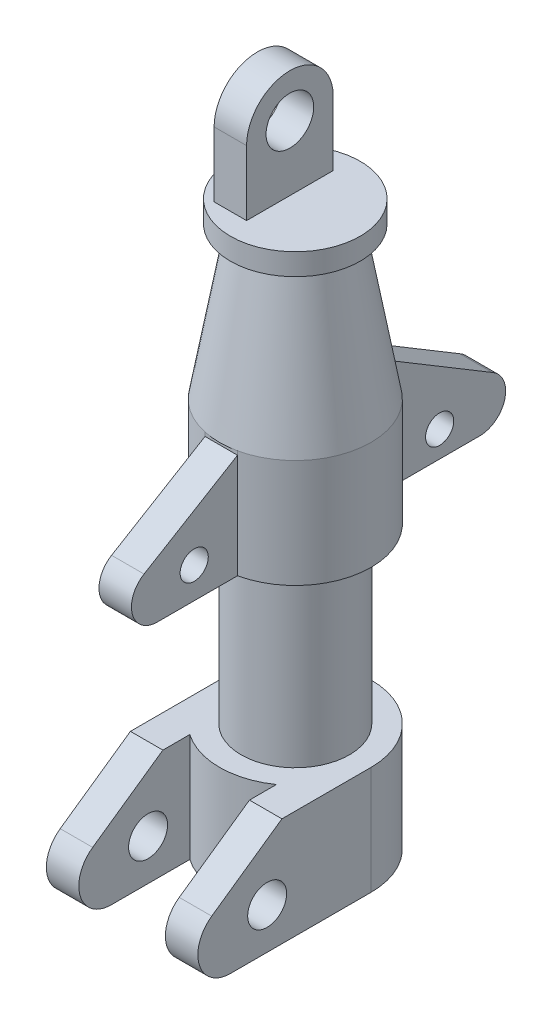
from build123d import *

# Parameters (mm, degrees)
SKETCH2_W           = 15
SKETCH2_H           = 93.194890567
BOSS_EXTRUDE2_DEPTH = 50
SKETCH3_R           = 9
CUT_EXTRUDE6_DEPTH  = 105
BOSS_EXTRUDE4_DEPTH = 50
SKETCH7_R           = 6.5
CUT_EXTRUDE7_DEPTH  = 105
SKETCH8_R           = 20
CUT_EXTRUDE8_DEPTH  = 235
SKETCH11_W          = 15
SKETCH11_H          = 40
BOSS_EXTRUDE5_DEPTH = 60
SKETCH12_R          = 11
CUT_EXTRUDE9_DEPTH  = 60


with BuildPart() as part:
    # Sketch1 → Revolve1 (revolve)
    with BuildSketch(Plane.XY):
        Polygon((0, 260), (30, 260), (30, 250), (22.65711135, 250), (35, 180), (35, 130), (25, 130), (25, 50), (35, 50), (35, 0), (0, 0), align=None)
    revolve(axis=Axis((0, 462.148353897, 0), (0, -1, 0)))

    # Sketch2 → Boss-Extrude2 (add)
    with BuildSketch(Plane(origin=(0, 0, 0), x_dir=(1, 0, 0), z_dir=(0, 1, 0))):
        with Locations((-27.5, -46.597445284)):
            Rectangle(SKETCH2_W, SKETCH2_H)
        with Locations((27.5, -46.597445284)):
            Rectangle(SKETCH2_W, SKETCH2_H)
    extrude(amount=BOSS_EXTRUDE2_DEPTH)

    # Sketch3 → Cut-Extrude6 (cut)
    with BuildSketch(Plane.ZY.offset(35)):
        with Locations((48, 19)):
            Circle(SKETCH3_R)
        with BuildLine():
            Line((73.603646545, 27.287280664), (41.166521698, 50))
            Line((41.166521698, 50), (93.194890567, 50))
            Line((93.194890567, 50), (93.194890567, 0))
            Line((93.194890567, 0), (65, 0))
            ThreePointArc((65, 0), (79.305754261, 10.489413007), (73.603646545, 27.287280664))
        make_face()
    extrude(amount=-CUT_EXTRUDE6_DEPTH, mode=Mode.SUBTRACT)

    # Sketch6 → Boss-Extrude4 (add)
    with BuildSketch(Plane(origin=(0, 180, 0), x_dir=(1, 0, 0), z_dir=(0, 1, 0))):
        Polygon((0, 0), (7.5, 0), (7.5, -91.66287292), (-7.5, -91.66287292), (-7.5, 0), align=None)
        Polygon((7.5, 91.66287292), (7.5, 9.253142795), (-7.5, 9.974305291), (-7.5, 91.66287292), align=None)
    extrude(amount=-BOSS_EXTRUDE4_DEPTH)

    # Sketch7 → Cut-Extrude7 (cut)
    with BuildSketch(Plane.ZY.offset(7.5)):
        with BuildLine():
            ThreePointArc((-83.531871553, 152.480329712), (-89.300855909, 138.980393779), (-77.686985828, 130))
            Line((-77.686985828, 130), (-91.66287292, 130))
            Line((-91.66287292, 130), (-91.66287292, 180))
            Line((-91.66287292, 180), (-37.731448931, 180))
            Line((-37.731448931, 180), (-83.531871553, 152.480329712))
        make_face()
        with BuildLine():
            Line((34.186985828, 180), (34.186985828, 178.231443671))
            Line((34.186985828, 178.231443671), (77.367442727, 152.286007608))
            ThreePointArc((77.367442727, 152.286007608), (82.750551266, 138.793139487), (71.186985828, 130))
            Line((71.186985828, 130), (91.66287292, 130))
            Line((91.66287292, 130), (91.66287292, 180))
            Line((91.66287292, 180), (34.186985828, 180))
        make_face()
        with Locations((54.186985828, 144.29)):
            Circle(SKETCH7_R)
        with Locations((-59.186985828, 142)):
            Circle(SKETCH7_R)
    extrude(amount=-CUT_EXTRUDE7_DEPTH, mode=Mode.SUBTRACT)

    # Sketch8 → Cut-Extrude8 (cut)
    with BuildSketch(Plane.XZ):
        Circle(SKETCH8_R)
    extrude(amount=-CUT_EXTRUDE8_DEPTH, mode=Mode.SUBTRACT)

    # Sketch11 → Boss-Extrude5 (add)
    with BuildSketch(Plane(origin=(0, 260, 0), x_dir=(1, 0, 0), z_dir=(0, 1, 0))):
        with Locations((-10, 0)):
            Rectangle(SKETCH11_W, SKETCH11_H)
    extrude(amount=BOSS_EXTRUDE5_DEPTH)

    # Sketch12 → Cut-Extrude9 (cut)
    with BuildSketch(Plane.ZY.offset(17.5)):
        with Locations((0, 290)):
            Circle(SKETCH12_R)
        with BuildLine():
            Line((-20, 290), (-20, 320))
            Line((-20, 320), (20, 320))
            Line((20, 320), (20, 290))
            ThreePointArc((20, 290), (0, 310), (-20, 290))
        make_face()
    extrude(amount=-CUT_EXTRUDE9_DEPTH, mode=Mode.SUBTRACT)


solid = part.part
